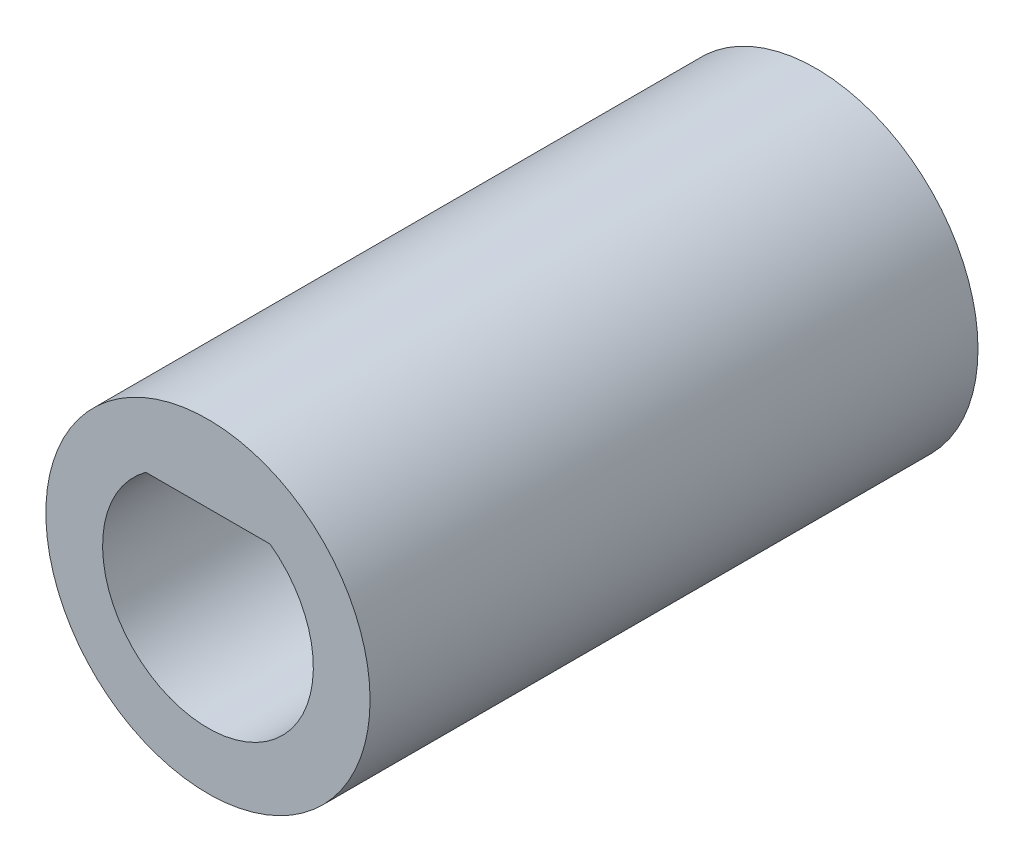
from build123d import *

# Parameters (mm, degrees)
CROQUIS1_R              = 4
SALIENTE_EXTRUIR1_DEPTH = 7.5
CORTAR_EXTRUIR1_DEPTH   = 7.5
CORTAR_EXTRUIR2_DEPTH   = 7.5


with BuildPart() as part:
    # Croquis1 → Saliente-Extruir1 (new body, symmetric)
    with BuildSketch(Plane.XY):
        Circle(CROQUIS1_R)
    extrude(amount=SALIENTE_EXTRUIR1_DEPTH, both=True)

    # Croquis2 → Cortar-Extruir1 (cut)
    with BuildSketch(Plane.XY.offset(7.5)):
        with BuildLine():
            Line((-1.532970972, 2.1), (1.532970972, 2.1))
            ThreePointArc((1.532970972, 2.1), (0, -2.6), (-1.532970972, 2.1))
        make_face()
    extrude(amount=-CORTAR_EXTRUIR1_DEPTH, mode=Mode.SUBTRACT)

    # Croquis3 → Cortar-Extruir2 (cut)
    with BuildSketch(Plane(origin=(0, 0, -7.5), x_dir=(-1, 0, 0), z_dir=(0, 0, -1))):
        with BuildLine():
            Line((-2.928736929, 0.65), (2.928736929, 0.65))
            ThreePointArc((2.928736929, 0.65), (0, 3), (-2.928736929, 0.65))
        make_face()
        with BuildLine():
            Line((-2.928736929, -0.65), (2.928736929, -0.65))
            ThreePointArc((2.928736929, -0.65), (0, -3), (-2.928736929, -0.65))
        make_face()
    extrude(amount=-CORTAR_EXTRUIR2_DEPTH, mode=Mode.SUBTRACT)


solid = part.part
